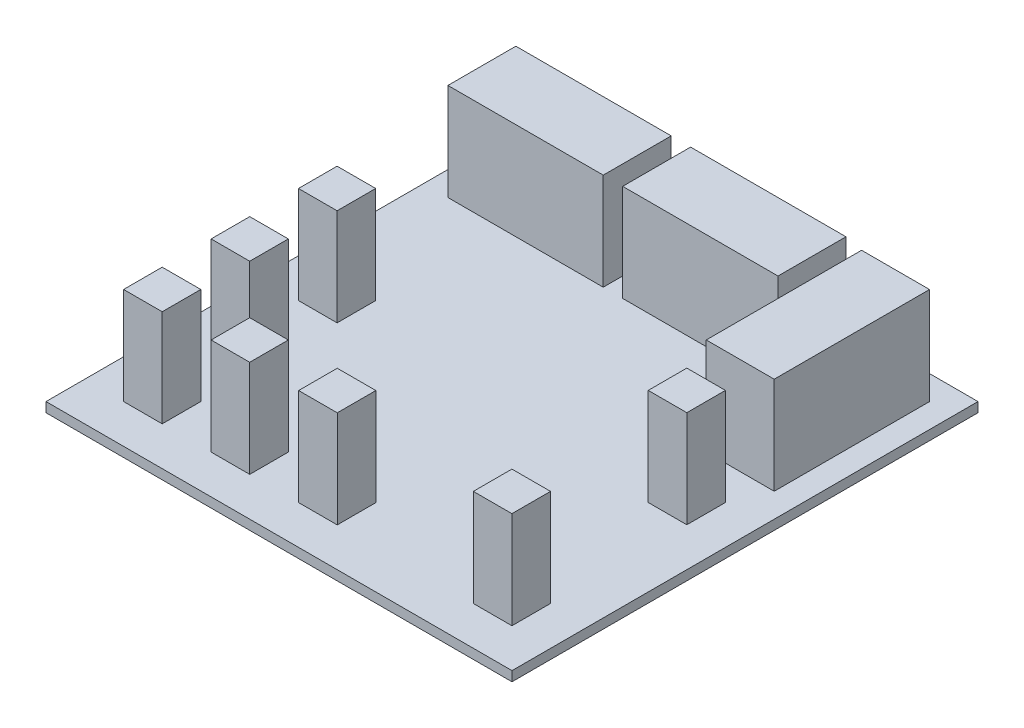
from build123d import *

# Parameters (mm, degrees)
SKETCH1_W              = 1.01
SKETCH1_H              = 1.01
BOSS_EXTRUDE1_DEPTH    = 2.54
BOSS_EXTRUDE1_2_DEPTH  = 2.54
BOSS_EXTRUDE1_3_DEPTH  = 2.54
BOSS_EXTRUDE1_4_DEPTH  = 2.54
BOSS_EXTRUDE1_5_DEPTH  = 2.54
BOSS_EXTRUDE1_6_DEPTH  = 2.54
BOSS_EXTRUDE1_7_DEPTH  = 2.54
SKETCH1_W_2            = 1.778
SKETCH1_H_2            = 4.064
BOSS_EXTRUDE1_8_DEPTH  = 2.54
SKETCH1_W_3            = 4.064
SKETCH1_H_3            = 1.778
BOSS_EXTRUDE1_9_DEPTH  = 2.54
BOSS_EXTRUDE1_10_DEPTH = 2.54
SKETCH3_W              = 12.192
SKETCH3_H              = 12.192
BOSS_EXTRUDE2_DEPTH    = 0.254


with BuildPart() as part:
    # Sketch1 (on Top Plane) → Boss-Extrude1 (new body)
    with BuildSketch(Plane(origin=(0, 0, 0), x_dir=(1, 0, 0), z_dir=(0, 1, 0))):
        with Locations((1.52, 1.52)):
            Rectangle(SKETCH1_W, SKETCH1_H)
    extrude(amount=BOSS_EXTRUDE1_DEPTH)



with BuildPart() as body_2:
    # Sketch1 (on Top Plane) → Boss-Extrude1 2 (new body)
    with BuildSketch(Plane(origin=(0, 0, 0), x_dir=(1, 0, 0), z_dir=(0, 1, 0))):
        with Locations((1.52, 6.096)):
            Rectangle(SKETCH1_W, SKETCH1_H)
    extrude(amount=BOSS_EXTRUDE1_2_DEPTH)


with BuildPart() as body_3:
    # Sketch1 (on Top Plane) → Boss-Extrude1 3 (new body)
    with BuildSketch(Plane(origin=(0, 0, 0), x_dir=(1, 0, 0), z_dir=(0, 1, 0))):
        with Locations((1.52, 3.81)):
            Rectangle(SKETCH1_W, SKETCH1_H)
    extrude(amount=BOSS_EXTRUDE1_3_DEPTH)


with BuildPart() as body_4:
    # Sketch1 (on Top Plane) → Boss-Extrude1 4 (new body)
    with BuildSketch(Plane(origin=(0, 0, 0), x_dir=(1, 0, 0), z_dir=(0, 1, 0))):
        with Locations((10.67, 1.52)):
            Rectangle(SKETCH1_W, SKETCH1_H)
    extrude(amount=BOSS_EXTRUDE1_4_DEPTH)


with BuildPart() as body_5:
    # Sketch1 (on Top Plane) → Boss-Extrude1 5 (new body)
    with BuildSketch(Plane(origin=(0, 0, 0), x_dir=(1, 0, 0), z_dir=(0, 1, 0))):
        with Locations((6.1, 1.52)):
            Rectangle(SKETCH1_W, SKETCH1_H)
    extrude(amount=BOSS_EXTRUDE1_5_DEPTH)


with BuildPart() as body_6:
    # Sketch1 (on Top Plane) → Boss-Extrude1 6 (new body)
    with BuildSketch(Plane(origin=(0, 0, 0), x_dir=(1, 0, 0), z_dir=(0, 1, 0))):
        with Locations((3.81, 1.52)):
            Rectangle(SKETCH1_W, SKETCH1_H)
    extrude(amount=BOSS_EXTRUDE1_6_DEPTH)


with BuildPart() as body_7:
    # Sketch1 (on Top Plane) → Boss-Extrude1 7 (new body)
    with BuildSketch(Plane(origin=(0, 0, 0), x_dir=(1, 0, 0), z_dir=(0, 1, 0))):
        with Locations((10.67, 6.096)):
            Rectangle(SKETCH1_W, SKETCH1_H)
    extrude(amount=BOSS_EXTRUDE1_7_DEPTH)


with BuildPart() as body_8:
    # Sketch1 (on Top Plane) → Boss-Extrude1 8 (new body)
    with BuildSketch(Plane(origin=(0, 0, 0), x_dir=(1, 0, 0), z_dir=(0, 1, 0))):
        with Locations((10.67, 9.525)):
            Rectangle(SKETCH1_W_2, SKETCH1_H_2)
    extrude(amount=BOSS_EXTRUDE1_8_DEPTH)


with BuildPart() as body_9:
    # Sketch1 (on Top Plane) → Boss-Extrude1 9 (new body)
    with BuildSketch(Plane(origin=(0, 0, 0), x_dir=(1, 0, 0), z_dir=(0, 1, 0))):
        with Locations((2.667, 10.769327267)):
            Rectangle(SKETCH1_W_3, SKETCH1_H_3)
    extrude(amount=BOSS_EXTRUDE1_9_DEPTH)


with BuildPart() as body_10:
    # Sketch1 (on Top Plane) → Boss-Extrude1 10 (new body)
    with BuildSketch(Plane(origin=(0, 0, 0), x_dir=(1, 0, 0), z_dir=(0, 1, 0))):
        with Locations((7.239, 10.769327267)):
            Rectangle(SKETCH1_W_3, SKETCH1_H_3)
    extrude(amount=BOSS_EXTRUDE1_10_DEPTH)


with BuildPart() as part_1:
    add(part.part)

    add(body_2.part)  # Boss-Extrude2 merges body 2

    add(body_3.part)  # Boss-Extrude2 merges body 3

    add(body_4.part)  # Boss-Extrude2 merges body 4

    add(body_5.part)  # Boss-Extrude2 merges body 5

    add(body_6.part)  # Boss-Extrude2 merges body 6

    add(body_7.part)  # Boss-Extrude2 merges body 7

    add(body_8.part)  # Boss-Extrude2 merges body 8

    add(body_9.part)  # Boss-Extrude2 merges body 9

    add(body_10.part)  # Boss-Extrude2 merges body 10
    # Sketch3 → Boss-Extrude2 (add)
    with BuildSketch(Plane.XZ):
        with Locations((6.096, -6.096)):
            Rectangle(SKETCH3_W, SKETCH3_H)
    extrude(amount=BOSS_EXTRUDE2_DEPTH)


solid = part_1.part
